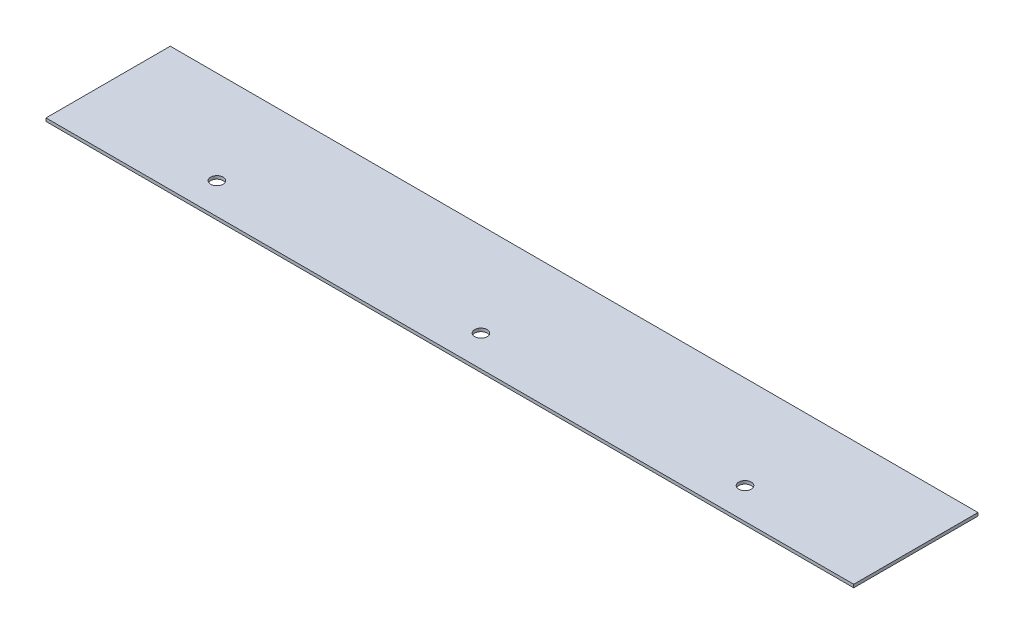
from build123d import *

# Parameters (mm, degrees)
SKETCH1_4_W         = 260
SKETCH1_4_H         = 40
SKETCH1_4_R         = 2
BOSS_EXTRUDE3_DEPTH = 1


with BuildPart() as part:
    # Sketch1_4 → Boss-Extrude3 (new body)
    with BuildSketch(Plane(origin=(0, 0, 0), x_dir=(1, 0, 0), z_dir=(0, 1, 0))):
        with Locations((0, 10)):
            Rectangle(SKETCH1_4_W, SKETCH1_4_H)
        with Locations((-85, 0)):
            Circle(SKETCH1_4_R, mode=Mode.SUBTRACT)
        Circle(SKETCH1_4_R, mode=Mode.SUBTRACT)
        with Locations((85, 0)):
            Circle(SKETCH1_4_R, mode=Mode.SUBTRACT)
    extrude(amount=BOSS_EXTRUDE3_DEPTH)


solid = part.part
